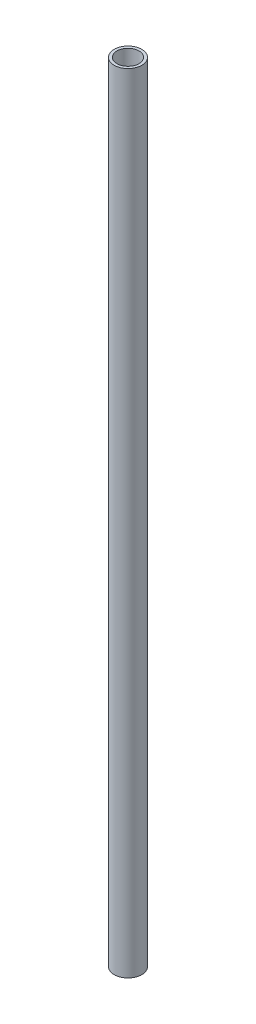
from build123d import *

# Parameters (mm, degrees)
SKETCH_1_R          = 12.5
EXTRUDE_1_DEPTH     = 356
SKETCH_2_R          = 10
CUT_EXTRUDE_1_DEPTH = 20
SKETCH_3_R          = 3
CUT_EXTRUDE_2_DEPTH = 800
SKETCH_4_R          = 12
CUT_EXTRUDE_3_DEPTH = 20


with BuildPart() as part:
    # 草图1 → 凸台-拉伸1 (new body, symmetric)
    with BuildSketch(Plane(origin=(0, 0, 0), x_dir=(1, 0, 0), z_dir=(0, 1, 0))):
        Circle(SKETCH_1_R)
    extrude(amount=EXTRUDE_1_DEPTH, both=True)

    # 草图2 → 切除-拉伸1 (cut)
    with BuildSketch(Plane(origin=(0, 356, 0), x_dir=(1, 0, 0), z_dir=(0, 1, 0))):
        Circle(SKETCH_2_R)
    extrude(amount=-CUT_EXTRUDE_1_DEPTH, mode=Mode.SUBTRACT)

    # 草图3 → 切除-拉伸2 (cut)
    with BuildSketch(Plane(origin=(0, 356, 0), x_dir=(1, 0, 0), z_dir=(0, 1, 0))):
        Circle(SKETCH_3_R)
    extrude(amount=-CUT_EXTRUDE_2_DEPTH, mode=Mode.SUBTRACT)

    # 草图4 → 切除-拉伸3 (cut)
    with BuildSketch(Plane.XZ.offset(356)):
        Circle(SKETCH_4_R)
    extrude(amount=-CUT_EXTRUDE_3_DEPTH, mode=Mode.SUBTRACT)


solid = part.part
